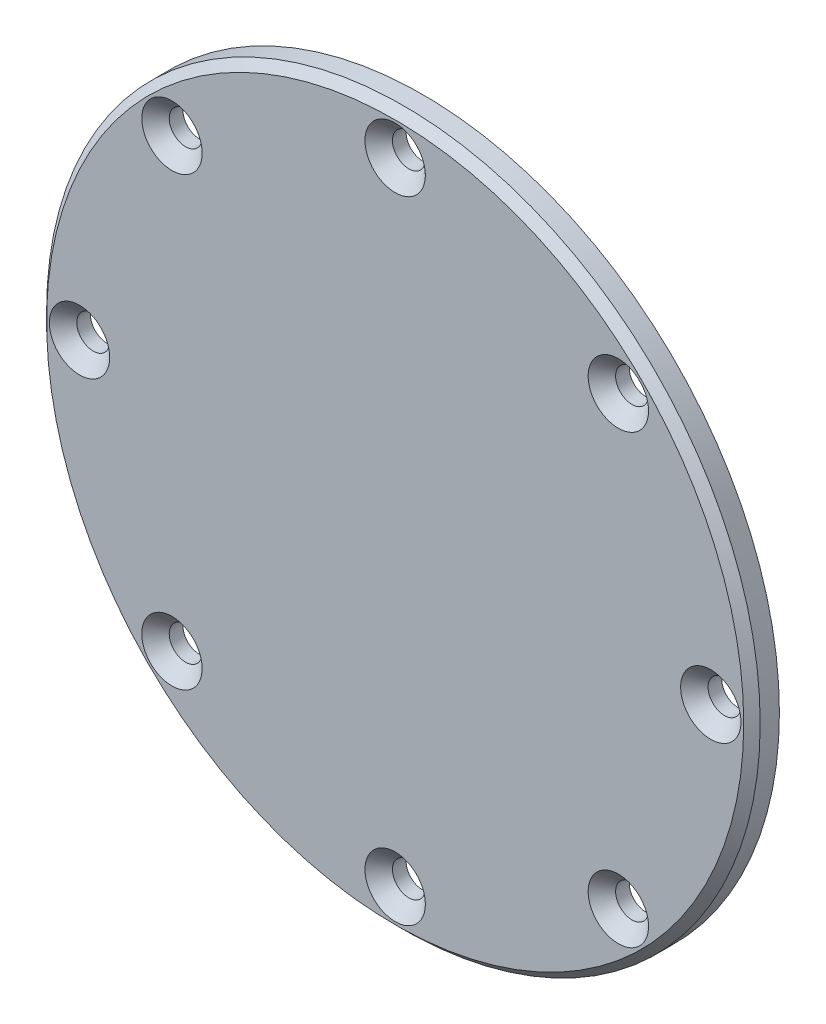
from build123d import *

# Parameters (mm, degrees)
SKETCH_1_R               = 26
EXTRUDE_1_DEPTH          = 2
CHAMFER_2_SIZE           = 0.6
PATTERN_CIRCULAR_1_COUNT = 8


with BuildPart() as part:
    # Эскиз1 → Бобышка-Вытянуть1 (new body)
    with BuildSketch(Plane.XY):
        Circle(SKETCH_1_R)
    extrude(amount=EXTRUDE_1_DEPTH)

    # Фаска2
    chamfer_2_edges = [part.edges().sort_by_distance(p)[0] for p in [
        (-26, 0, 2),
    ]]
    chamfer(chamfer_2_edges, length=CHAMFER_2_SIZE)

    # Эскиз3 → Зенковка для винта с полупотайной головкой M21 (revolve, cut)
    with BuildSketch(Plane(origin=(-23, 0, 2), x_dir=(0, -1, 0), z_dir=(1, 0, 0))):
        Polygon((0, 0), (0, 6.721032743), (1.2, 6), (1.2, 1), (2.2, 0), align=None)
    hole_wizard_m21 = revolve(axis=Axis((-23, 0, 8.35), (0, 0, -1)), mode=Mode.SUBTRACT)

    # Круговой массив1: Зенковка для винта с полупотайной головкой M21 ×8 about axis
    pattern_circular_1_axis = Axis((0, 0, 0), (0, 0, 1))
    for i in range(1, PATTERN_CIRCULAR_1_COUNT):
        add(hole_wizard_m21.rotate(pattern_circular_1_axis, i * 360 / PATTERN_CIRCULAR_1_COUNT), mode=Mode.SUBTRACT)


solid = part.part
